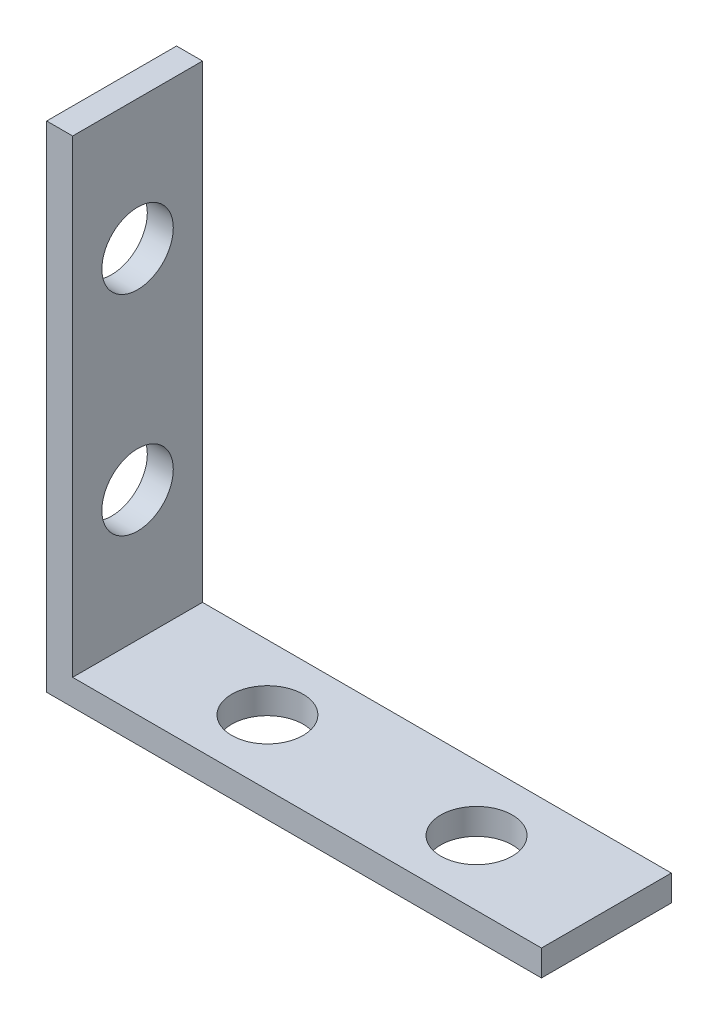
from build123d import *

# Parameters (mm, degrees)
BOSS_EXTRUDE1_DEPTH            = 10
M5_CLEARANCE_HOLE4_D           = 5.5
M5_CLEARANCE_HOLE4_ON_FACE_2_D = 5.5


with BuildPart() as part:
    # Sketch1 → Boss-Extrude1 (new body)
    with BuildSketch(Plane.XY):
        Polygon((0, 0), (38.1, 0), (38.1, 2), (2, 2), (2, 38.1), (0, 38.1), align=None)
    extrude(amount=BOSS_EXTRUDE1_DEPTH)

    # M5 Clearance Hole4 (through all)
    with Locations(Plane(origin=(2, 12, 5), x_dir=(0, 1, 0), z_dir=(1, 0, 0))):
        with Locations((0, 0), (16.1, 0)):
            Hole(M5_CLEARANCE_HOLE4_D / 2)

    # M5 Clearance Hole4 on face 2 (through all)
    with Locations(Plane(origin=(12, 2, 5), x_dir=(0, 0, 1), z_dir=(0, 1, 0))):
        with Locations((0, 0), (0, 16.1)):
            Hole(M5_CLEARANCE_HOLE4_ON_FACE_2_D / 2)


solid = part.part
